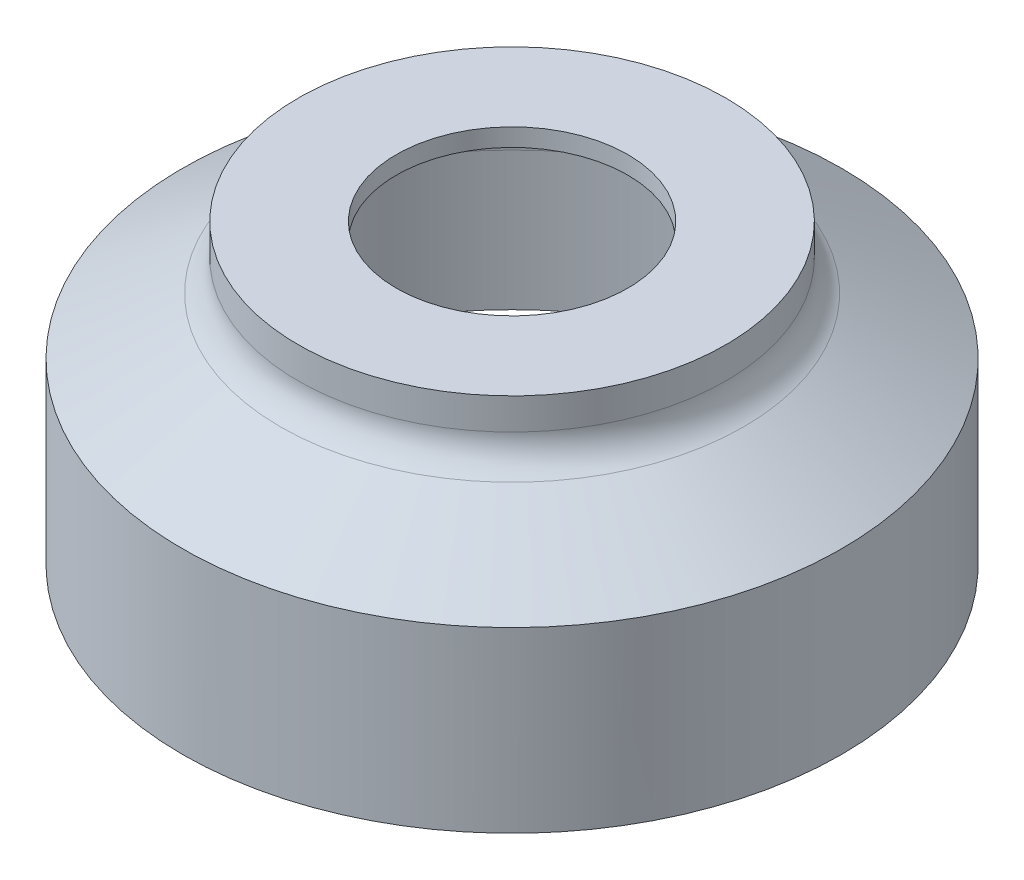
from build123d import *

# Parameters (mm, degrees)
SKETCH1_R           = 14.097
BOSS_EXTRUDE1_DEPTH = 12.7


with BuildPart() as part:
    # Sketch1 → Boss-Extrude1 (new body)
    with BuildSketch(Plane(origin=(0, 0, 0), x_dir=(1, 0, 0), z_dir=(0, 1, 0))):
        with Locations(Location((0, 0, 0), (0, 0, 270))):  # turned: the seam where the file's is
            Circle(SKETCH1_R)
    extrude(amount=BOSS_EXTRUDE1_DEPTH)

    # Sketch2 → Cut-Revolve1 (revolve, cut)
    with BuildSketch(Plane.XY, mode=Mode.PRIVATE) as cut_revolve1_sk:
        with BuildLine():
            Line((4.953, 12.7), (4.953, 11.938))
            Line((4.953, 11.938), (8.382, 11.938))
            Line((8.382, 11.938), (8.382, 9.652))
            Line((8.382, 9.652), (12.573, 7.232325022))
            ThreePointArc((12.573, 7.232325022), (13.130822715, 6.674502306), (13.335, 5.912502306))
            Line((13.335, 5.912502306), (13.335, 0))
            Line((13.335, 0), (0, 0))
            Line((0, 0), (0, 12.7))
            Line((0, 12.7), (4.953, 12.7))
        make_face()
    revolve(cut_revolve1_sk.sketch.rotate(Axis((0, 0, 0), (0, 1, 0)), 90), axis=Axis((0, 0, 0), (0, 1, 0)), mode=Mode.SUBTRACT)  # turned: the seam where the file's is

    # Sketch3 → Cut-Revolve2 (revolve, cut)
    with BuildSketch(Plane.XY, mode=Mode.PRIVATE) as cut_revolve2_sk:
        with BuildLine():
            Line((14.097, 12.7), (14.097, 7.62))
            Line((14.097, 7.62), (9.906, 10.039674978))
            ThreePointArc((9.906, 10.039674978), (9.348177285, 10.597497694), (9.144, 11.359497694))
            Line((9.144, 11.359497694), (9.144, 12.7))
            Line((9.144, 12.7), (14.097, 12.7))
        make_face()
    revolve(cut_revolve2_sk.sketch.rotate(Axis((0, 0, 0), (0, 1, 0)), 90), axis=Axis((0, 0, 0), (0, 1, 0)), mode=Mode.SUBTRACT)  # turned: the seam where the file's is


solid = part.part
